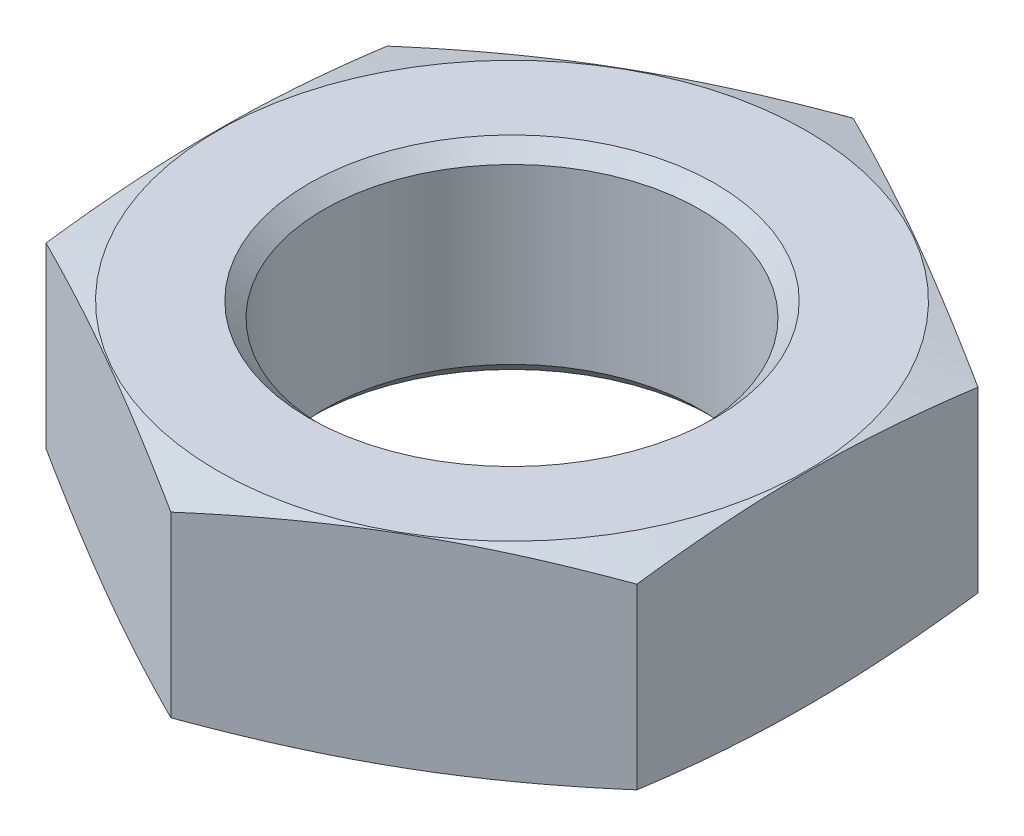
from build123d import *

# Parameters (mm, degrees)
SCHNITT_LINEAR_AUSTRAGEN1_DEPTH      = 12
SCHNITT_LINEAR_AUSTRAGEN1_DEPTH_BACK = 12
SKIZZE2_W                            = 128
SKIZZE2_H                            = 128


with BuildPart() as part:
    # Skizze1 → Rotation1 (revolve)
    with BuildSketch(Plane.XY):
        Polygon((0, 0), (15.95, 0), (36.476279442, -5.5), (15.95, -11), (0, -11), align=None)
    revolve(axis=Axis((0, -11, 0), (0, 1, 0)))

    # Skizze2 → Schnitt-Linear austragen1 (cut, two sides: drawn at the far end of the back side and taken through both)
    with BuildSketch(Plane(origin=(0, 0, 0), x_dir=(1, 0, 0), z_dir=(0, 1, 0)).offset(-SCHNITT_LINEAR_AUSTRAGEN1_DEPTH_BACK)):
        Rectangle(SKIZZE2_W, SKIZZE2_H)
        Polygon((-16, -9.237604307), (0, -18.475208614), (16, -9.237604307), (16, 9.237604307), (0, 18.475208614), (-16, 9.237604307), align=None, mode=Mode.SUBTRACT)
    extrude(amount=SCHNITT_LINEAR_AUSTRAGEN1_DEPTH + SCHNITT_LINEAR_AUSTRAGEN1_DEPTH_BACK, mode=Mode.SUBTRACT)

    # Skizze3 → Schnitt-Rotation1 (revolve, cut)
    with BuildSketch(Plane.XY):
        Polygon((0, 0), (11, 0), (10.188, -0.812), (10.188, -10.188), (11, -11), (0, -11), align=None)
    revolve(axis=Axis((0, -11, 0), (0, 1, 0)), mode=Mode.SUBTRACT)


solid = part.part
